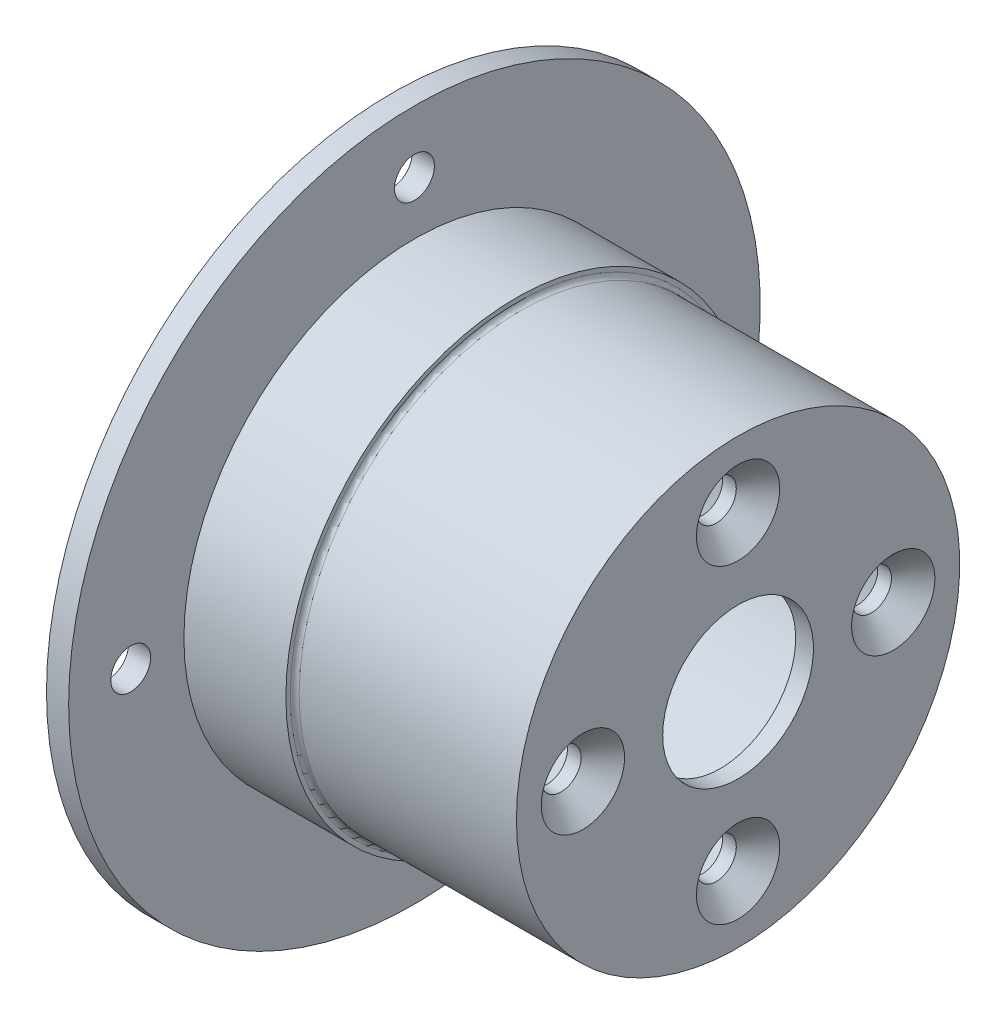
from build123d import *

# Parameters (mm, degrees)
CSK_FOR_M4_FLAT_HEAD_MACHINE_SCREW1_AT_2_COUNT = 2
CSK_FOR_M4_FLAT_HEAD_MACHINE_SCREW1_AT_2_PITCH = 24.748737342
CSK_FOR_M4_FLAT_HEAD_MACHINE_SCREW1_AT_3_COUNT = 2
CSK_FOR_M4_FLAT_HEAD_MACHINE_SCREW1_AT_3_PITCH = 35
CSK_FOR_M4_FLAT_HEAD_MACHINE_SCREW1_AT_4_COUNT = 2
CSK_FOR_M4_FLAT_HEAD_MACHINE_SCREW1_AT_4_PITCH = 24.748737342
M4_CLEARANCE_HOLE1_D                           = 4.5
M4_CLEARANCE_HOLE1_DEPTH                       = 2.5
FILLET1_R                                      = 0.5


with BuildPart() as part:
    # Sketch2 → Revolve1 (revolve)
    with BuildSketch(Plane.XY):
        Polygon((0, 21), (35, 21), (35, 12.5), (37, 12.5), (37, 8.5), (39, 8.5), (39, 25), (14, 25), (14, 26), (2.5, 26), (2.5, 39), (0, 39), (0, 26), align=None)
    revolve(axis=Axis((-64.103352454, 0, 0), (1, 0, 0)))

    # Sketch8 → CSK for M4 Flat Head Machine Screw1 (revolve, cut)
    with BuildSketch(Plane(origin=(39, 17.5, 0), x_dir=(0, 0, -1), z_dir=(0, 1, 0))):
        Polygon((0, 0), (0, 4), (2.25, 4), (2.25, 2.45), (4.7, 0), align=None)
    csk_for_m4_flat_head_machine_screw1 = revolve(axis=Axis((45.35, 17.5, 0), (-1, 0, 0)), mode=Mode.SUBTRACT)

    # CSK for M4 Flat Head Machine Screw1 at 2: CSK for M4 Flat Head Machine Screw1 ×2
    with Locations(*[Vector(0, -0.707106781, -0.707106781) * (i * CSK_FOR_M4_FLAT_HEAD_MACHINE_SCREW1_AT_2_PITCH) for i in range(1, CSK_FOR_M4_FLAT_HEAD_MACHINE_SCREW1_AT_2_COUNT)]):
        add(csk_for_m4_flat_head_machine_screw1, mode=Mode.SUBTRACT)

    # CSK for M4 Flat Head Machine Screw1 at 3: CSK for M4 Flat Head Machine Screw1 ×2
    with Locations(*[(0, -i * CSK_FOR_M4_FLAT_HEAD_MACHINE_SCREW1_AT_3_PITCH, 0) for i in range(1, CSK_FOR_M4_FLAT_HEAD_MACHINE_SCREW1_AT_3_COUNT)]):
        add(csk_for_m4_flat_head_machine_screw1, mode=Mode.SUBTRACT)

    # CSK for M4 Flat Head Machine Screw1 at 4: CSK for M4 Flat Head Machine Screw1 ×2
    with Locations(*[Vector(0, -0.707106781, 0.707106781) * (i * CSK_FOR_M4_FLAT_HEAD_MACHINE_SCREW1_AT_4_PITCH) for i in range(1, CSK_FOR_M4_FLAT_HEAD_MACHINE_SCREW1_AT_4_COUNT)]):
        add(csk_for_m4_flat_head_machine_screw1, mode=Mode.SUBTRACT)

    # M4 Clearance Hole1
    with Locations(Plane.ZY):
        with Locations((0, 32), (0, -32), (32, 0), (-32, 0)):
            Hole(M4_CLEARANCE_HOLE1_D / 2, depth=M4_CLEARANCE_HOLE1_DEPTH)

    # Fillet1
    fillet1_edges = [part.edges().sort_by_distance(p)[0] for p in [
        (14, -25, 0),
    ]]
    fillet(fillet1_edges, radius=FILLET1_R)


solid = part.part
